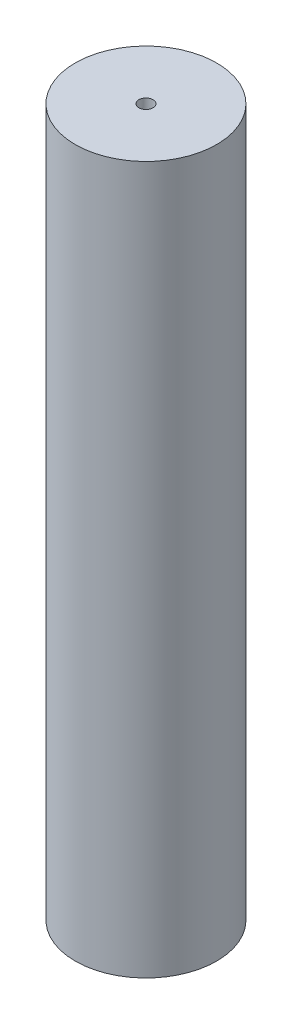
from build123d import *

# Parameters (mm, degrees)
SKETCH1_R           = 100
BOSS_EXTRUDE2_DEPTH = 1000
SKETCH2_R           = 10
CUT_EXTRUDE1_DEPTH  = 20


with BuildPart() as part:
    # Sketch1 → Boss-Extrude2 (new body)
    with BuildSketch(Plane(origin=(0, 0, 0), x_dir=(1, 0, 0), z_dir=(0, 1, 0))):
        Circle(SKETCH1_R)
    extrude(amount=BOSS_EXTRUDE2_DEPTH)

    # Sketch2 → Cut-Extrude1 (cut)
    with BuildSketch(Plane(origin=(0, 1000, 0), x_dir=(1, 0, 0), z_dir=(0, 1, 0))):
        Circle(SKETCH2_R)
    extrude(amount=-CUT_EXTRUDE1_DEPTH, mode=Mode.SUBTRACT)


solid = part.part
